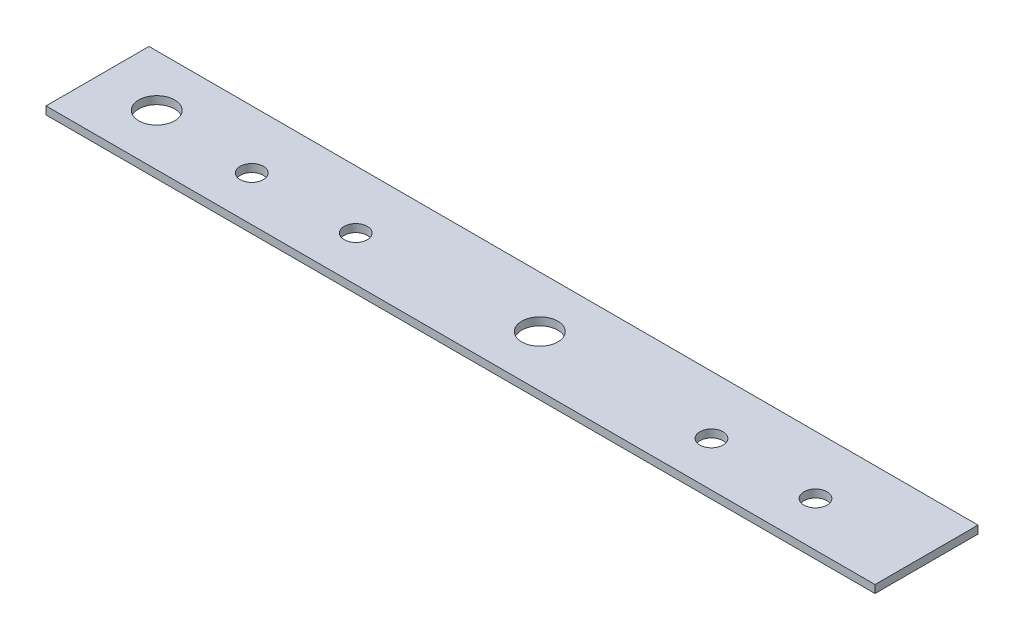
from build123d import *

# Parameters (mm, degrees)
SKETCH1_W           = 80.5
SKETCH1_H           = 10
SKETCH1_R           = 1.75
SKETCH1_R_2         = 1.125
BOSS_EXTRUDE1_DEPTH = 0.38


with BuildPart() as part:
    # Sketch1 → Boss-Extrude1 (new body, symmetric)
    with BuildSketch(Plane(origin=(0, 0, 0), x_dir=(1, 0, 0), z_dir=(0, 1, 0))):
        Rectangle(SKETCH1_W, SKETCH1_H)
        with Locations(Location((-34.5, 0, 0), (0, 0, 270))):  # turned: the seam where the file's is
            Circle(SKETCH1_R, mode=Mode.SUBTRACT)
        with Locations(Location((-14.52, -0.65, 0), (0, 0, 270))):  # turned: the seam where the file's is
            Circle(SKETCH1_R_2, mode=Mode.SUBTRACT)
        with Locations(Location((-24.62, -0.65, 0), (0, 0, 270))):  # turned: the seam where the file's is
            Circle(SKETCH1_R_2, mode=Mode.SUBTRACT)
        with Locations(Location((2.7, 0, 0), (0, 0, 270))):  # turned: the seam where the file's is
            Circle(SKETCH1_R, mode=Mode.SUBTRACT)
        with Locations(Location((20.02, -0.65, 0), (0, 0, 270))):  # turned: the seam where the file's is
            Circle(SKETCH1_R_2, mode=Mode.SUBTRACT)
        with Locations(Location((30.12, -0.65, 0), (0, 0, 270))):  # turned: the seam where the file's is
            Circle(SKETCH1_R_2, mode=Mode.SUBTRACT)
    extrude(amount=BOSS_EXTRUDE1_DEPTH, both=True)


solid = part.part
